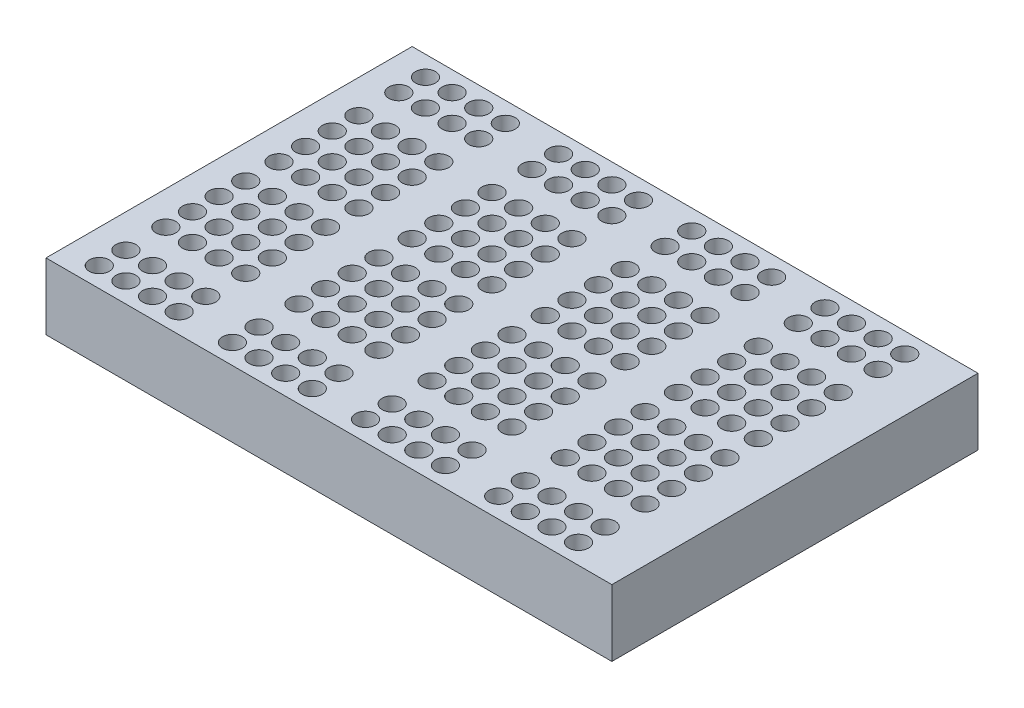
from build123d import *

# Parameters (mm, degrees)
SKETCH1_W           = 85
SKETCH1_H           = 55
BOSS_EXTRUDE1_DEPTH = 10
SKETCH2_R           = 1.5
CUT_EXTRUDE1_DEPTH  = 7


with BuildPart() as part:
    # Sketch1 → Boss-Extrude1 (new body)
    with BuildSketch(Plane(origin=(0, 0, 0), x_dir=(1, 0, 0), z_dir=(0, 1, 0))):
        Rectangle(SKETCH1_W, SKETCH1_H)
    extrude(amount=BOSS_EXTRUDE1_DEPTH)

    # Sketch2 → Cut-Extrude1 (cut)
    with BuildSketch(Plane(origin=(0, 10, 0), x_dir=(1, 0, 0), z_dir=(0, 1, 0))):
        with Locations((-37.5, 24.5)):
            Circle(SKETCH2_R)
        with Locations((-33.5, 24.5)):
            Circle(SKETCH2_R)
        with Locations((-29.5, 24.5)):
            Circle(SKETCH2_R)
        with Locations((-25.5, 24.5)):
            Circle(SKETCH2_R)
        with Locations((-17.5, 24.5)):
            Circle(SKETCH2_R)
        with Locations((-13.5, 24.5)):
            Circle(SKETCH2_R)
        with Locations((-9.5, 24.5)):
            Circle(SKETCH2_R)
        with Locations((-5.5, 24.5)):
            Circle(SKETCH2_R)
        with Locations((2.5, 24.5)):
            Circle(SKETCH2_R)
        with Locations((6.5, 24.5)):
            Circle(SKETCH2_R)
        with Locations((10.5, 24.5)):
            Circle(SKETCH2_R)
        with Locations((14.5, 24.5)):
            Circle(SKETCH2_R)
        with Locations((22.5, 24.5)):
            Circle(SKETCH2_R)
        with Locations((26.5, 24.5)):
            Circle(SKETCH2_R)
        with Locations((30.5, 24.5)):
            Circle(SKETCH2_R)
        with Locations((34.5, 24.5)):
            Circle(SKETCH2_R)
        with Locations((-37.5, 20.5)):
            Circle(SKETCH2_R)
        with Locations((-33.5, 20.5)):
            Circle(SKETCH2_R)
        with Locations((-29.5, 20.5)):
            Circle(SKETCH2_R)
        with Locations((-25.5, 20.5)):
            Circle(SKETCH2_R)
        with Locations((-17.5, 20.5)):
            Circle(SKETCH2_R)
        with Locations((-13.5, 20.5)):
            Circle(SKETCH2_R)
        with Locations((-9.5, 20.5)):
            Circle(SKETCH2_R)
        with Locations((-5.5, 20.5)):
            Circle(SKETCH2_R)
        with Locations((2.5, 20.5)):
            Circle(SKETCH2_R)
        with Locations((6.5, 20.5)):
            Circle(SKETCH2_R)
        with Locations((10.5, 20.5)):
            Circle(SKETCH2_R)
        with Locations((14.5, 20.5)):
            Circle(SKETCH2_R)
        with Locations((22.5, 20.5)):
            Circle(SKETCH2_R)
        with Locations((26.5, 20.5)):
            Circle(SKETCH2_R)
        with Locations((30.5, 20.5)):
            Circle(SKETCH2_R)
        with Locations((34.5, 20.5)):
            Circle(SKETCH2_R)
        with Locations((34.5, -20.5)):
            Circle(SKETCH2_R)
        with Locations((30.5, -20.5)):
            Circle(SKETCH2_R)
        with Locations((26.5, -20.5)):
            Circle(SKETCH2_R)
        with Locations((22.5, -20.5)):
            Circle(SKETCH2_R)
        with Locations((14.5, -20.5)):
            Circle(SKETCH2_R)
        with Locations((10.5, -20.5)):
            Circle(SKETCH2_R)
        with Locations((6.5, -20.5)):
            Circle(SKETCH2_R)
        with Locations((2.5, -20.5)):
            Circle(SKETCH2_R)
        with Locations((-5.5, -20.5)):
            Circle(SKETCH2_R)
        with Locations((-9.5, -20.5)):
            Circle(SKETCH2_R)
        with Locations((-13.5, -20.5)):
            Circle(SKETCH2_R)
        with Locations((-17.5, -20.5)):
            Circle(SKETCH2_R)
        with Locations((-25.5, -20.5)):
            Circle(SKETCH2_R)
        with Locations((-29.5, -20.5)):
            Circle(SKETCH2_R)
        with Locations((-33.5, -20.5)):
            Circle(SKETCH2_R)
        with Locations((-37.5, -20.5)):
            Circle(SKETCH2_R)
        with Locations((34.5, -24.5)):
            Circle(SKETCH2_R)
        with Locations((30.5, -24.5)):
            Circle(SKETCH2_R)
        with Locations((26.5, -24.5)):
            Circle(SKETCH2_R)
        with Locations((22.5, -24.5)):
            Circle(SKETCH2_R)
        with Locations((14.5, -24.5)):
            Circle(SKETCH2_R)
        with Locations((10.5, -24.5)):
            Circle(SKETCH2_R)
        with Locations((6.5, -24.5)):
            Circle(SKETCH2_R)
        with Locations((2.5, -24.5)):
            Circle(SKETCH2_R)
        with Locations((-5.5, -24.5)):
            Circle(SKETCH2_R)
        with Locations((-9.5, -24.5)):
            Circle(SKETCH2_R)
        with Locations((-13.5, -24.5)):
            Circle(SKETCH2_R)
        with Locations((-17.5, -24.5)):
            Circle(SKETCH2_R)
        with Locations((-25.5, -24.5)):
            Circle(SKETCH2_R)
        with Locations((-29.5, -24.5)):
            Circle(SKETCH2_R)
        with Locations((-33.5, -24.5)):
            Circle(SKETCH2_R)
        with Locations((-37.5, -24.5)):
            Circle(SKETCH2_R)
        with Locations((-37.5, 14.5)):
            Circle(SKETCH2_R)
        with Locations((-33.5, 14.5)):
            Circle(SKETCH2_R)
        with Locations((-29.5, 14.5)):
            Circle(SKETCH2_R)
        with Locations((-25.5, 14.5)):
            Circle(SKETCH2_R)
        with Locations((-17.5, 14.5)):
            Circle(SKETCH2_R)
        with Locations((-13.5, 14.5)):
            Circle(SKETCH2_R)
        with Locations((-9.5, 14.5)):
            Circle(SKETCH2_R)
        with Locations((-5.5, 14.5)):
            Circle(SKETCH2_R)
        with Locations((2.5, 14.5)):
            Circle(SKETCH2_R)
        with Locations((6.5, 14.5)):
            Circle(SKETCH2_R)
        with Locations((10.5, 14.5)):
            Circle(SKETCH2_R)
        with Locations((14.5, 14.5)):
            Circle(SKETCH2_R)
        with Locations((22.5, 14.5)):
            Circle(SKETCH2_R)
        with Locations((26.5, 14.5)):
            Circle(SKETCH2_R)
        with Locations((30.5, 14.5)):
            Circle(SKETCH2_R)
        with Locations((34.5, 14.5)):
            Circle(SKETCH2_R)
        with Locations((-37.5, 10.5)):
            Circle(SKETCH2_R)
        with Locations((-33.5, 10.5)):
            Circle(SKETCH2_R)
        with Locations((-29.5, 10.5)):
            Circle(SKETCH2_R)
        with Locations((-25.5, 10.5)):
            Circle(SKETCH2_R)
        with Locations((-17.5, 10.5)):
            Circle(SKETCH2_R)
        with Locations((-13.5, 10.5)):
            Circle(SKETCH2_R)
        with Locations((-9.5, 10.5)):
            Circle(SKETCH2_R)
        with Locations((-5.5, 10.5)):
            Circle(SKETCH2_R)
        with Locations((2.5, 10.5)):
            Circle(SKETCH2_R)
        with Locations((6.5, 10.5)):
            Circle(SKETCH2_R)
        with Locations((10.5, 10.5)):
            Circle(SKETCH2_R)
        with Locations((14.5, 10.5)):
            Circle(SKETCH2_R)
        with Locations((22.5, 10.5)):
            Circle(SKETCH2_R)
        with Locations((26.5, 10.5)):
            Circle(SKETCH2_R)
        with Locations((30.5, 10.5)):
            Circle(SKETCH2_R)
        with Locations((34.5, 10.5)):
            Circle(SKETCH2_R)
        with Locations((-37.5, 6.5)):
            Circle(SKETCH2_R)
        with Locations((-33.5, 6.5)):
            Circle(SKETCH2_R)
        with Locations((-29.5, 6.5)):
            Circle(SKETCH2_R)
        with Locations((-25.5, 6.5)):
            Circle(SKETCH2_R)
        with Locations((-17.5, 6.5)):
            Circle(SKETCH2_R)
        with Locations((-13.5, 6.5)):
            Circle(SKETCH2_R)
        with Locations((-9.5, 6.5)):
            Circle(SKETCH2_R)
        with Locations((-5.5, 6.5)):
            Circle(SKETCH2_R)
        with Locations((2.5, 6.5)):
            Circle(SKETCH2_R)
        with Locations((6.5, 6.5)):
            Circle(SKETCH2_R)
        with Locations((10.5, 6.5)):
            Circle(SKETCH2_R)
        with Locations((14.5, 6.5)):
            Circle(SKETCH2_R)
        with Locations((22.5, 6.5)):
            Circle(SKETCH2_R)
        with Locations((26.5, 6.5)):
            Circle(SKETCH2_R)
        with Locations((30.5, 6.5)):
            Circle(SKETCH2_R)
        with Locations((34.5, 6.5)):
            Circle(SKETCH2_R)
        with Locations((-37.5, 2.5)):
            Circle(SKETCH2_R)
        with Locations((-33.5, 2.5)):
            Circle(SKETCH2_R)
        with Locations((-29.5, 2.5)):
            Circle(SKETCH2_R)
        with Locations((-25.5, 2.5)):
            Circle(SKETCH2_R)
        with Locations((-17.5, 2.5)):
            Circle(SKETCH2_R)
        with Locations((-13.5, 2.5)):
            Circle(SKETCH2_R)
        with Locations((-9.5, 2.5)):
            Circle(SKETCH2_R)
        with Locations((-5.5, 2.5)):
            Circle(SKETCH2_R)
        with Locations((2.5, 2.5)):
            Circle(SKETCH2_R)
        with Locations((6.5, 2.5)):
            Circle(SKETCH2_R)
        with Locations((10.5, 2.5)):
            Circle(SKETCH2_R)
        with Locations((14.5, 2.5)):
            Circle(SKETCH2_R)
        with Locations((22.5, 2.5)):
            Circle(SKETCH2_R)
        with Locations((26.5, 2.5)):
            Circle(SKETCH2_R)
        with Locations((30.5, 2.5)):
            Circle(SKETCH2_R)
        with Locations((34.5, 2.5)):
            Circle(SKETCH2_R)
        with Locations((34.5, -2.5)):
            Circle(SKETCH2_R)
        with Locations((30.5, -2.5)):
            Circle(SKETCH2_R)
        with Locations((26.5, -2.5)):
            Circle(SKETCH2_R)
        with Locations((22.5, -2.5)):
            Circle(SKETCH2_R)
        with Locations((14.5, -2.5)):
            Circle(SKETCH2_R)
        with Locations((10.5, -2.5)):
            Circle(SKETCH2_R)
        with Locations((6.5, -2.5)):
            Circle(SKETCH2_R)
        with Locations((2.5, -2.5)):
            Circle(SKETCH2_R)
        with Locations((-5.5, -2.5)):
            Circle(SKETCH2_R)
        with Locations((-9.5, -2.5)):
            Circle(SKETCH2_R)
        with Locations((-13.5, -2.5)):
            Circle(SKETCH2_R)
        with Locations((-17.5, -2.5)):
            Circle(SKETCH2_R)
        with Locations((-25.5, -2.5)):
            Circle(SKETCH2_R)
        with Locations((-29.5, -2.5)):
            Circle(SKETCH2_R)
        with Locations((-33.5, -2.5)):
            Circle(SKETCH2_R)
        with Locations((-37.5, -2.5)):
            Circle(SKETCH2_R)
        with Locations((34.5, -6.5)):
            Circle(SKETCH2_R)
        with Locations((30.5, -6.5)):
            Circle(SKETCH2_R)
        with Locations((26.5, -6.5)):
            Circle(SKETCH2_R)
        with Locations((22.5, -6.5)):
            Circle(SKETCH2_R)
        with Locations((14.5, -6.5)):
            Circle(SKETCH2_R)
        with Locations((10.5, -6.5)):
            Circle(SKETCH2_R)
        with Locations((6.5, -6.5)):
            Circle(SKETCH2_R)
        with Locations((2.5, -6.5)):
            Circle(SKETCH2_R)
        with Locations((-5.5, -6.5)):
            Circle(SKETCH2_R)
        with Locations((-9.5, -6.5)):
            Circle(SKETCH2_R)
        with Locations((-13.5, -6.5)):
            Circle(SKETCH2_R)
        with Locations((-17.5, -6.5)):
            Circle(SKETCH2_R)
        with Locations((-25.5, -6.5)):
            Circle(SKETCH2_R)
        with Locations((-29.5, -6.5)):
            Circle(SKETCH2_R)
        with Locations((-33.5, -6.5)):
            Circle(SKETCH2_R)
        with Locations((-37.5, -6.5)):
            Circle(SKETCH2_R)
        with Locations((34.5, -10.5)):
            Circle(SKETCH2_R)
        with Locations((30.5, -10.5)):
            Circle(SKETCH2_R)
        with Locations((26.5, -10.5)):
            Circle(SKETCH2_R)
        with Locations((22.5, -10.5)):
            Circle(SKETCH2_R)
        with Locations((14.5, -10.5)):
            Circle(SKETCH2_R)
        with Locations((10.5, -10.5)):
            Circle(SKETCH2_R)
        with Locations((6.5, -10.5)):
            Circle(SKETCH2_R)
        with Locations((2.5, -10.5)):
            Circle(SKETCH2_R)
        with Locations((-5.5, -10.5)):
            Circle(SKETCH2_R)
        with Locations((-9.5, -10.5)):
            Circle(SKETCH2_R)
        with Locations((-13.5, -10.5)):
            Circle(SKETCH2_R)
        with Locations((-17.5, -10.5)):
            Circle(SKETCH2_R)
        with Locations((-25.5, -10.5)):
            Circle(SKETCH2_R)
        with Locations((-29.5, -10.5)):
            Circle(SKETCH2_R)
        with Locations((-33.5, -10.5)):
            Circle(SKETCH2_R)
        with Locations((-37.5, -10.5)):
            Circle(SKETCH2_R)
        with Locations((34.5, -14.5)):
            Circle(SKETCH2_R)
        with Locations((30.5, -14.5)):
            Circle(SKETCH2_R)
        with Locations((26.5, -14.5)):
            Circle(SKETCH2_R)
        with Locations((22.5, -14.5)):
            Circle(SKETCH2_R)
        with Locations((14.5, -14.5)):
            Circle(SKETCH2_R)
        with Locations((10.5, -14.5)):
            Circle(SKETCH2_R)
        with Locations((6.5, -14.5)):
            Circle(SKETCH2_R)
        with Locations((2.5, -14.5)):
            Circle(SKETCH2_R)
        with Locations((-5.5, -14.5)):
            Circle(SKETCH2_R)
        with Locations((-9.5, -14.5)):
            Circle(SKETCH2_R)
        with Locations((-13.5, -14.5)):
            Circle(SKETCH2_R)
        with Locations((-17.5, -14.5)):
            Circle(SKETCH2_R)
        with Locations((-25.5, -14.5)):
            Circle(SKETCH2_R)
        with Locations((-29.5, -14.5)):
            Circle(SKETCH2_R)
        with Locations((-33.5, -14.5)):
            Circle(SKETCH2_R)
        with Locations((-37.5, -14.5)):
            Circle(SKETCH2_R)
    extrude(amount=-CUT_EXTRUDE1_DEPTH, mode=Mode.SUBTRACT)


solid = part.part
